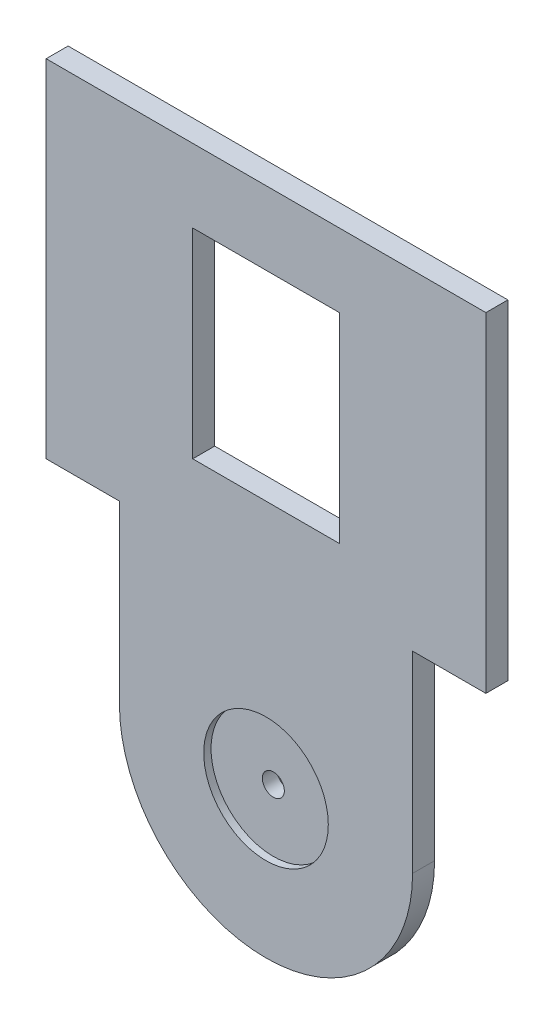
from build123d import *

# Parameters (mm, degrees)
CROQUIS1_R              = 1.5
CROQUIS1_W              = 20
CROQUIS1_H              = 27.278528679
SALIENTE_EXTRUIR1_DEPTH = 3
CROQUIS2_R              = 8.5
CORTAR_EXTRUIR1_DEPTH   = 1


with BuildPart() as part:
    # Croquis1 → Saliente-Extruir1 (new body)
    with BuildSketch(Plane.XY):
        with BuildLine():
            Line((-113.991811363, 10.970788205), (-113.991811363, 34.958108792))
            Line((-113.991811363, 34.958108792), (-123.991811363, 34.958108792))
            Line((-123.991811363, 34.958108792), (-123.991811363, 82.236637471))
            Line((-123.991811363, 82.236637471), (-63.991811363, 82.236637471))
            Line((-63.991811363, 82.236637471), (-63.991811363, 37.236637471))
            Line((-63.991811363, 37.236637471), (-73.991811363, 37.236637471))
            Line((-73.991811363, 37.236637471), (-73.991811363, 10.970788205))
            ThreePointArc((-73.991811363, 10.970788205), (-93.991811363, -9.029211795), (-113.991811363, 10.970788205))
        make_face()
        with Locations((-93.991811363, 10.970788205)):
            Circle(CROQUIS1_R, mode=Mode.SUBTRACT)
        with Locations((-93.991811363, 58.597373132)):
            Rectangle(CROQUIS1_W, CROQUIS1_H, mode=Mode.SUBTRACT)
    extrude(amount=SALIENTE_EXTRUIR1_DEPTH)

    # Croquis2 → Cortar-Extruir1 (cut)
    with BuildSketch(Plane.XY.offset(3)):
        with Locations((-93.991811363, 10.970788205)):
            Circle(CROQUIS2_R)
    extrude(amount=-CORTAR_EXTRUIR1_DEPTH, mode=Mode.SUBTRACT)


solid = part.part
